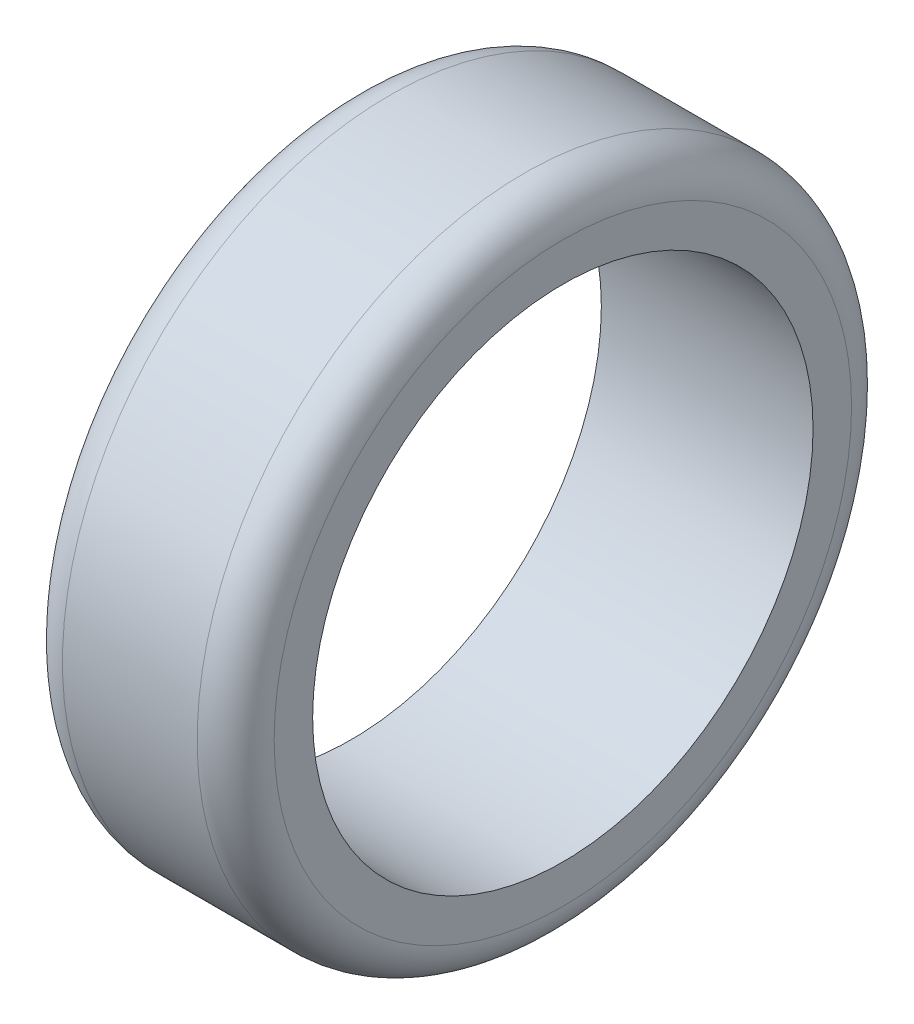
from build123d import *

# Parameters (mm, degrees)
SKETCH_1_R          = 34
EXTRUDE_1_DEPTH     = 22
SKETCH_2_R          = 26
CUT_EXTRUDE_1_DEPTH = 22
FILLET_1_R          = 4


with BuildPart() as part:
    # 草图1 → 凸台-拉伸1 (new body)
    with BuildSketch(Plane(origin=(0, 0, 0), x_dir=(0, 0, -1), z_dir=(1, 0, 0))):
        Circle(SKETCH_1_R)
    extrude(amount=EXTRUDE_1_DEPTH)

    # 草图2 → 切除-拉伸1 (cut)
    with BuildSketch(Plane.ZY):
        Circle(SKETCH_2_R)
    extrude(amount=-CUT_EXTRUDE_1_DEPTH, mode=Mode.SUBTRACT)

    # 圆角1
    fillet_1_edges = [part.edges().sort_by_distance(p)[0] for p in [
        (0, 0, 34),
        (22, 0, 34),
    ]]
    fillet(fillet_1_edges, radius=FILLET_1_R)


solid = part.part
